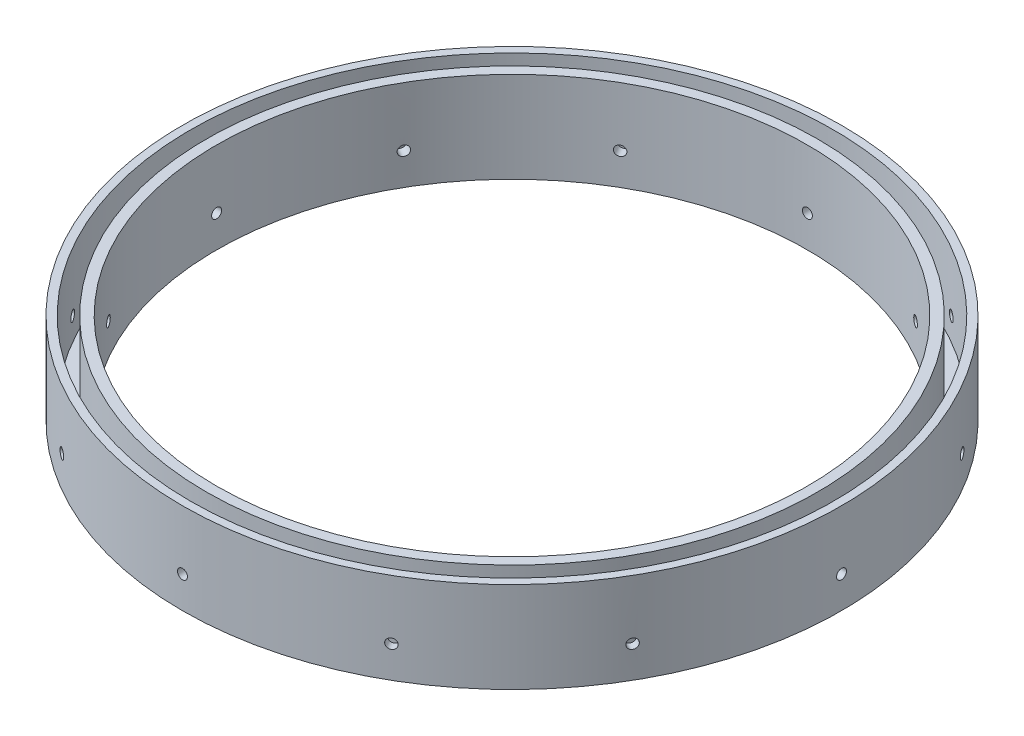
from build123d import *

# Parameters (mm, degrees)
SKETCH1_R           = 92.075
SKETCH1_R_2         = 82.55
BOSS_EXTRUDE1_DEPTH = 25.4
SKETCH2_R           = 89.8525
SKETCH2_R_2         = 85.4075
CUT_EXTRUDE1_DEPTH  = 22.86
CUT_EXTRUDE2_START  = -92.075
SKETCH3_R           = 1.3843
CUT_EXTRUDE2_DEPTH  = 9.536608
CIRPATTERN1_COUNT   = 12


with BuildPart() as part:
    # Sketch1 → Boss-Extrude1 (new body)
    with BuildSketch(Plane(origin=(0, 0, 0), x_dir=(1, 0, 0), z_dir=(0, 1, 0))):
        Circle(SKETCH1_R)
        Circle(SKETCH1_R_2, mode=Mode.SUBTRACT)
    extrude(amount=BOSS_EXTRUDE1_DEPTH)

    # Sketch2 → Cut-Extrude1 (cut)
    with BuildSketch(Plane(origin=(0, 25.4, 0), x_dir=(1, 0, 0), z_dir=(0, 1, 0))):
        Circle(SKETCH2_R)
        Circle(SKETCH2_R_2, mode=Mode.SUBTRACT)
    extrude(amount=-CUT_EXTRUDE1_DEPTH, mode=Mode.SUBTRACT)

    # Sketch3 → Cut-Extrude2 (cut)
    with BuildSketch(Plane.XY.offset(CUT_EXTRUDE2_START)):
        with Locations((0, 8.89)):
            Circle(SKETCH3_R)
    cut_extrude2 = extrude(amount=CUT_EXTRUDE2_DEPTH, mode=Mode.SUBTRACT)

    # CirPattern1: Cut-Extrude2 ×12 about axis
    cirpattern1_axis = Axis((0, 25.4, 0), (0, 1, 0))
    for i in range(1, CIRPATTERN1_COUNT):
        add(cut_extrude2.rotate(cirpattern1_axis, i * 360 / CIRPATTERN1_COUNT), mode=Mode.SUBTRACT)


solid = part.part
